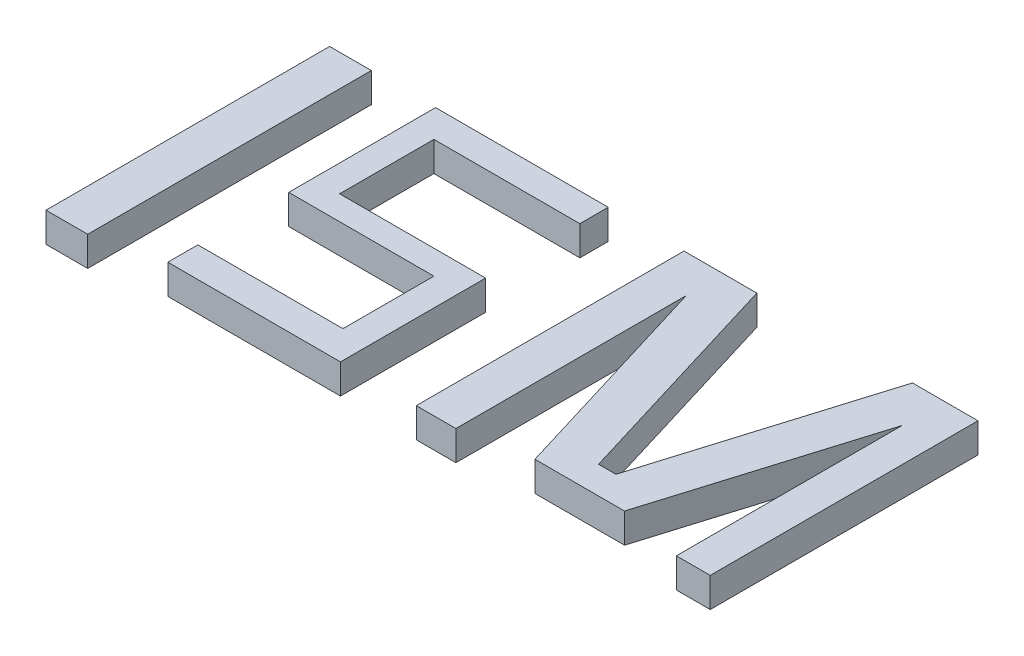
from build123d import *

# Parameters (mm, degrees)
SKETCH1_W             = 14.077534264
SKETCH1_H             = 95.727232995
BOSS_EXTRUDE1_DEPTH   = 10
BOSS_EXTRUDE1_2_DEPTH = 10
BOSS_EXTRUDE1_3_DEPTH = 10


with BuildPart() as part:
    # Sketch1 → Boss-Extrude1 (new body)
    with BuildSketch(Plane(origin=(0, 0, 0), x_dir=(1, 0, 0), z_dir=(0, 1, 0))):
        with Locations((-58.70331788, 4.082484937)):
            Rectangle(SKETCH1_W, SKETCH1_H)
    extrude(amount=BOSS_EXTRUDE1_DEPTH)


with BuildPart() as body_2:
    # Sketch1 → Boss-Extrude1 2 (new body)
    with BuildSketch(Plane(origin=(0, 0, 0), x_dir=(1, 0, 0), z_dir=(0, 1, 0))):
        Polygon((53.881234625, -38.43166854), (53.881234625, 51.946101434), (78.450636619, 51.946101434), (101.788622724, -24.807745079), (107.63617878, -24.807745079), (130.974164885, 51.946101434), (153.096678858, 51.946101434), (153.096678858, -38.43166854), (141.665334196, -38.43166854), (141.665334196, 37.749510192), (119.823976618, -34.082232257), (89.577457677, -34.082232257), (67.25598854, 39.328498573), (67.25598854, -38.43166854), align=None)
    extrude(amount=BOSS_EXTRUDE1_2_DEPTH)


with BuildPart() as body_3:
    # Sketch1 → Boss-Extrude1 3 (new body)
    with BuildSketch(Plane(origin=(0, 0, 0), x_dir=(1, 0, 0), z_dir=(0, 1, 0))):
        Polygon((28.29584387, 51.946101434), (-29.985147982, 51.946101434), (-29.985147982, 2.393180825), (19.004671256, 2.393180825), (19.004671256, -28.29584387), (-29.985147982, -28.29584387), (-29.985147982, -38.43166854), (28.29584387, -38.43166854), (28.29584387, 10.558150698), (-20.975526053, 10.558150698), (-20.975526053, 42.373378134), (28.29584387, 42.373378134), align=None)
    extrude(amount=BOSS_EXTRUDE1_3_DEPTH)


solid = Compound([part.part, body_2.part, body_3.part])
